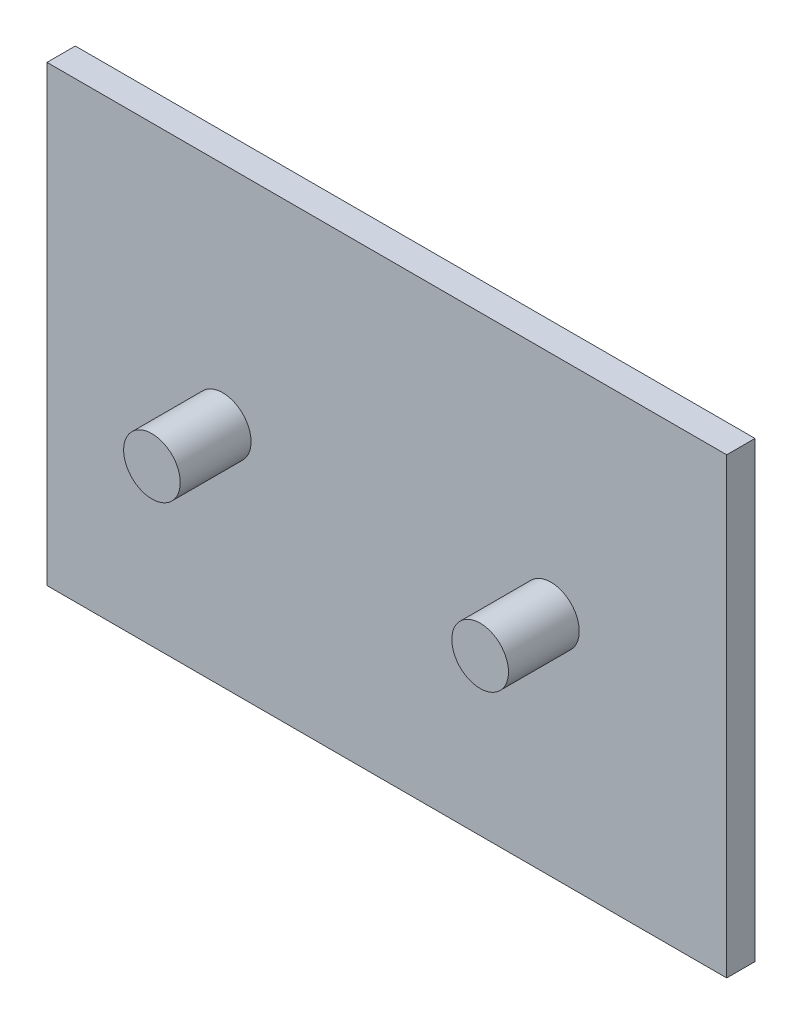
from build123d import *

# Parameters (mm, degrees)
SKETCH1_W           = 304.8
SKETCH1_H           = 203.2
BOSS_EXTRUDE1_DEPTH = 6.35
SKETCH2_R           = 12.7
BOSS_EXTRUDE2_DEPTH = 31.75


with BuildPart() as part:
    # Sketch1 → Boss-Extrude1 (new body, symmetric)
    with BuildSketch(Plane.XY):
        Rectangle(SKETCH1_W, SKETCH1_H)
    extrude(amount=BOSS_EXTRUDE1_DEPTH, both=True)

    # Sketch2 → Boss-Extrude2 (add)
    with BuildSketch(Plane.XY.offset(6.35)):
        with Locations((73.588104792, 0)):
            Circle(SKETCH2_R)
        with Locations((-73.588104792, 0)):
            Circle(SKETCH2_R)
    extrude(amount=BOSS_EXTRUDE2_DEPTH)


solid = part.part
